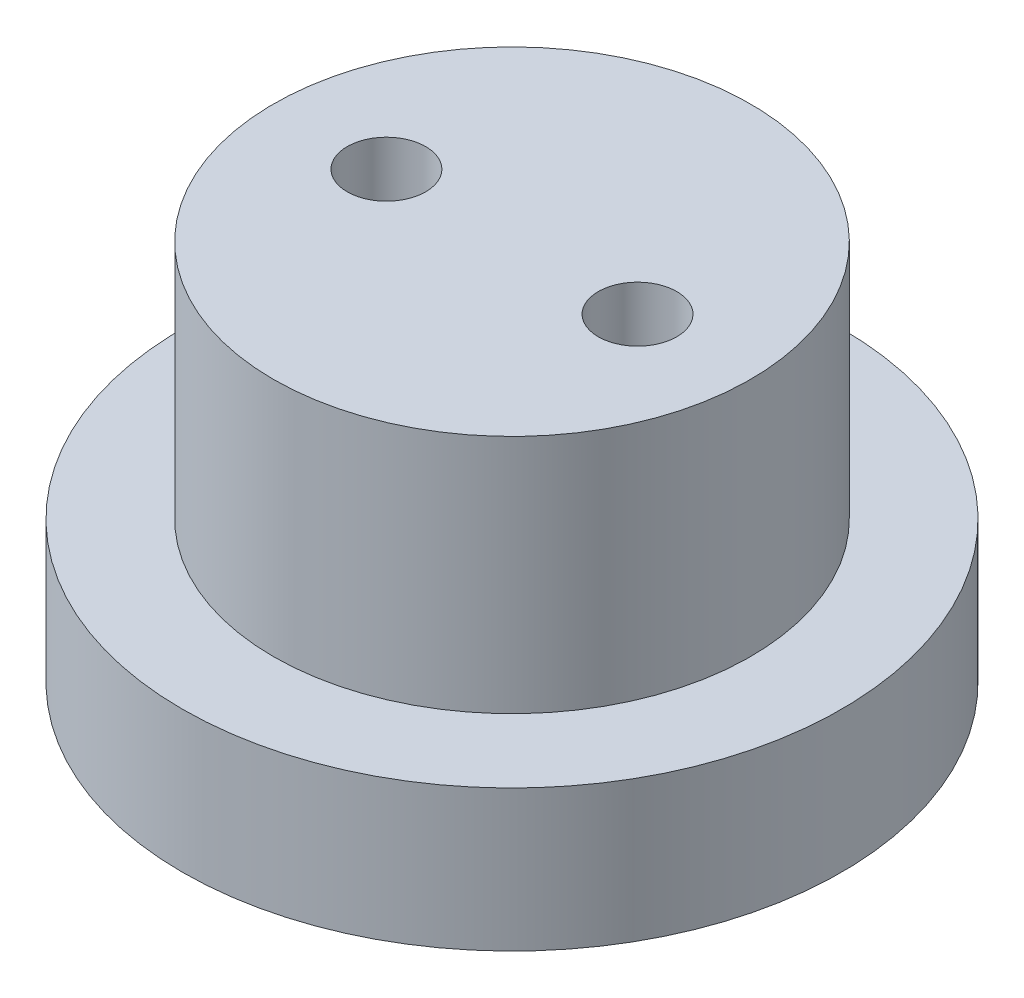
from build123d import *

# Parameters (mm, degrees)
SKETCH2_R           = 7.6
SKETCH2_R_2         = 1.25
BOSS_EXTRUDE2_DEPTH = 10.15
SKETCH3_R           = 10.5
SKETCH3_R_2         = 1.25
BOSS_EXTRUDE3_DEPTH = 2.5
SKETCH4_R           = 2.675
CUT_EXTRUDE1_DEPTH  = 2.15
SKETCH5_R           = 10.5
SKETCH5_R_2         = 2.675
BOSS_EXTRUDE4_DEPTH = 2


with BuildPart() as part:
    # Sketch2 → Boss-Extrude2 (new body)
    with BuildSketch(Plane(origin=(0, 0, 0), x_dir=(1, 0, 0), z_dir=(0, 1, 0))):
        Circle(SKETCH2_R)
        with Locations((4, 0)):
            Circle(SKETCH2_R_2, mode=Mode.SUBTRACT)
        with Locations((-4, 0)):
            Circle(SKETCH2_R_2, mode=Mode.SUBTRACT)
    extrude(amount=BOSS_EXTRUDE2_DEPTH)

    # Sketch3 → Boss-Extrude3 (add)
    with BuildSketch(Plane(origin=(0, 0, 0), x_dir=(1, 0, 0), z_dir=(0, 1, 0))):
        Circle(SKETCH3_R)
        with Locations((-4, 0)):
            Circle(SKETCH3_R_2, mode=Mode.SUBTRACT)
        with Locations((4, 0)):
            Circle(SKETCH3_R_2, mode=Mode.SUBTRACT)
    extrude(amount=BOSS_EXTRUDE3_DEPTH)

    # Sketch4 → Cut-Extrude1 (cut)
    with BuildSketch(Plane.XZ):
        with Locations((4, 0)):
            Circle(SKETCH4_R)
        with Locations((-4, 0)):
            Circle(SKETCH4_R)
    extrude(amount=-CUT_EXTRUDE1_DEPTH, mode=Mode.SUBTRACT)

    # Sketch5 → Boss-Extrude4 (add)
    with BuildSketch(Plane.XZ):
        Circle(SKETCH5_R)
        with Locations((-4, 0)):
            Circle(SKETCH5_R_2, mode=Mode.SUBTRACT)
        with Locations((4, 0)):
            Circle(SKETCH5_R_2, mode=Mode.SUBTRACT)
    extrude(amount=BOSS_EXTRUDE4_DEPTH)


solid = part.part
